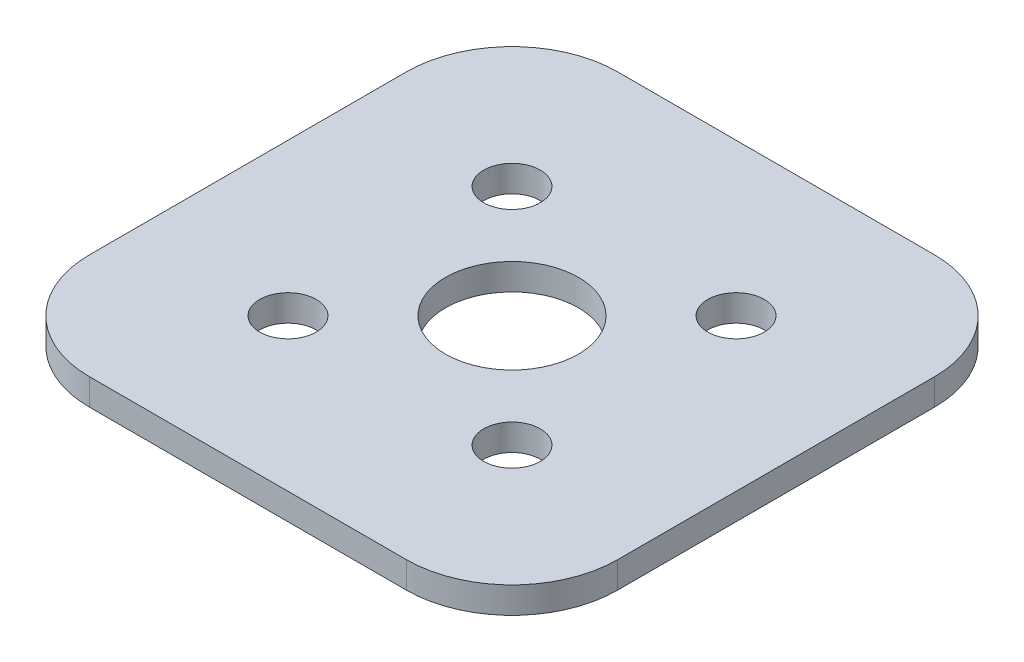
from build123d import *

# Parameters (mm, degrees)
SKETCH1_R           = 1.6999966
SKETCH1_R_2         = 4
BOSS_EXTRUDE1_DEPTH = 1.5875


with BuildPart() as part:
    # Sketch1 → Boss-Extrude1 (new body)
    with BuildSketch(Plane(origin=(0, 0, 0), x_dir=(1, 0, 0), z_dir=(0, 1, 0))):
        with BuildLine():
            Line((-9.525, 15.875), (9.525, 15.875))
            ThreePointArc((9.525, 15.875), (14.015128061, 14.015128061), (15.875, 9.525))
            Line((15.875, 9.525), (15.875, -9.525))
            ThreePointArc((15.875, -9.525), (14.015128061, -14.015128061), (9.525, -15.875))
            Line((9.525, -15.875), (-9.525, -15.875))
            ThreePointArc((-9.525, -15.875), (-14.015128061, -14.015128061), (-15.875, -9.525))
            Line((-15.875, -9.525), (-15.875, 9.525))
            ThreePointArc((-15.875, 9.525), (-14.015128061, 14.015128061), (-9.525, 15.875))
        make_face()
        with Locations((-6.735192091, -6.735192091)):
            Circle(SKETCH1_R, mode=Mode.SUBTRACT)
        with Locations((6.735192091, -6.735192091)):
            Circle(SKETCH1_R, mode=Mode.SUBTRACT)
        Circle(SKETCH1_R_2, mode=Mode.SUBTRACT)
        with Locations((6.735192091, 6.735192091)):
            Circle(SKETCH1_R, mode=Mode.SUBTRACT)
        with Locations((-6.735192091, 6.735192091)):
            Circle(SKETCH1_R, mode=Mode.SUBTRACT)
    extrude(amount=BOSS_EXTRUDE1_DEPTH)


solid = part.part
